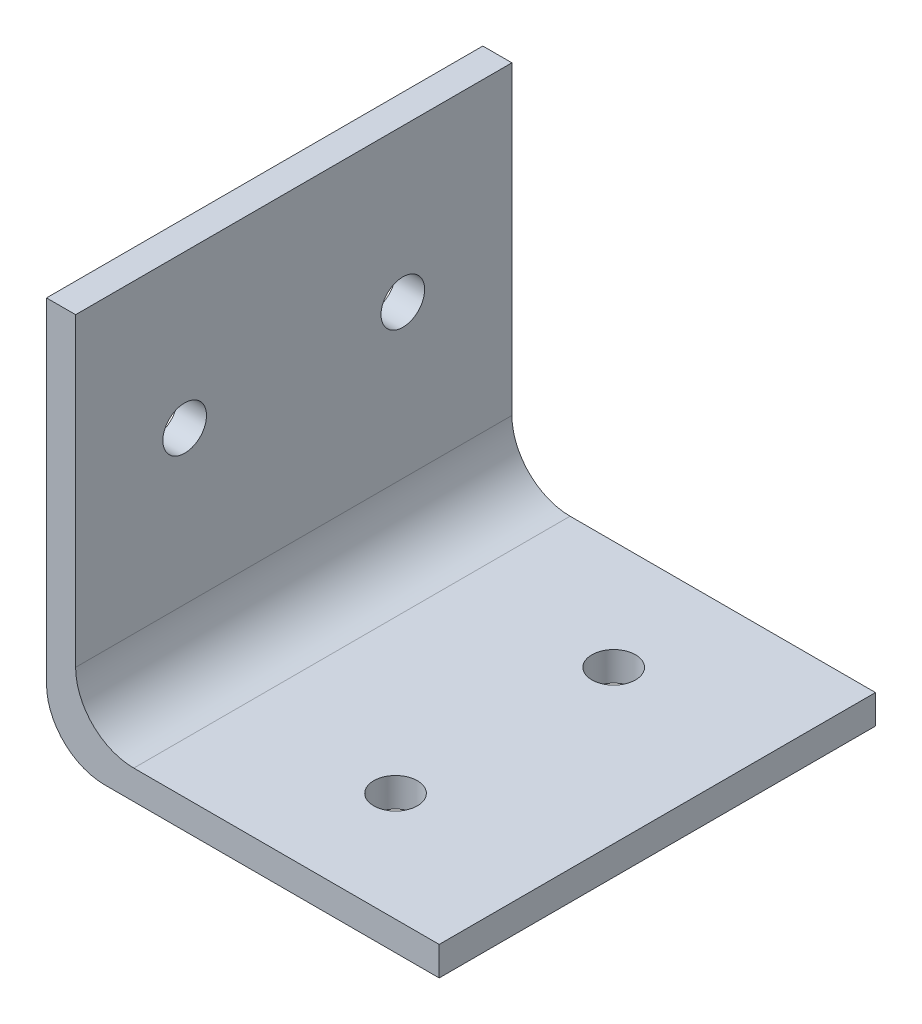
from build123d import *

# Parameters (mm, degrees)
BOSS_EXTRUDE1_DEPTH       = 30
FILLET1_R                 = 4
FILLET2_R                 = 4
F_3_0MM_DOWEL_HOLE1_D     = 3
F_3_0MM_DOWEL_HOLE1_DEPTH = 2
F_3_0MM_DOWEL_HOLE2_D     = 3
F_3_0MM_DOWEL_HOLE2_DEPTH = 2


with BuildPart() as part:
    # Sketch1 → Boss-Extrude1 (new body)
    with BuildSketch(Plane.XY):
        Polygon((0, 0), (25, 0), (25, -2), (-2, -2), (-2, 25), (0, 25), align=None)
    extrude(amount=-BOSS_EXTRUDE1_DEPTH)

    # Fillet1
    fillet1_edges = [part.edges().sort_by_distance(p)[0] for p in [
        (0, 0, -15),
    ]]
    fillet(fillet1_edges, radius=FILLET1_R)

    # Fillet2
    fillet2_edges = [part.edges().sort_by_distance(p)[0] for p in [
        (-2, -2, -15),
    ]]
    fillet(fillet2_edges, radius=FILLET2_R)

    # Ø3.0mm Dowel Hole1
    with Locations(Plane(origin=(0, 0, 0), x_dir=(1, 0, 0), z_dir=(0, 1, 0))):
        with Locations((14.5, 22.5), (14.5, 7.5)):
            Hole(F_3_0MM_DOWEL_HOLE1_D / 2, depth=F_3_0MM_DOWEL_HOLE1_DEPTH)

    # Ø3.0mm Dowel Hole2
    with Locations(Plane(origin=(0, 0, 0), x_dir=(0, 0, -1), z_dir=(1, 0, 0))):
        with Locations((7.5, 14.5), (22.5, 14.5)):
            Hole(F_3_0MM_DOWEL_HOLE2_D / 2, depth=F_3_0MM_DOWEL_HOLE2_DEPTH)


solid = part.part
